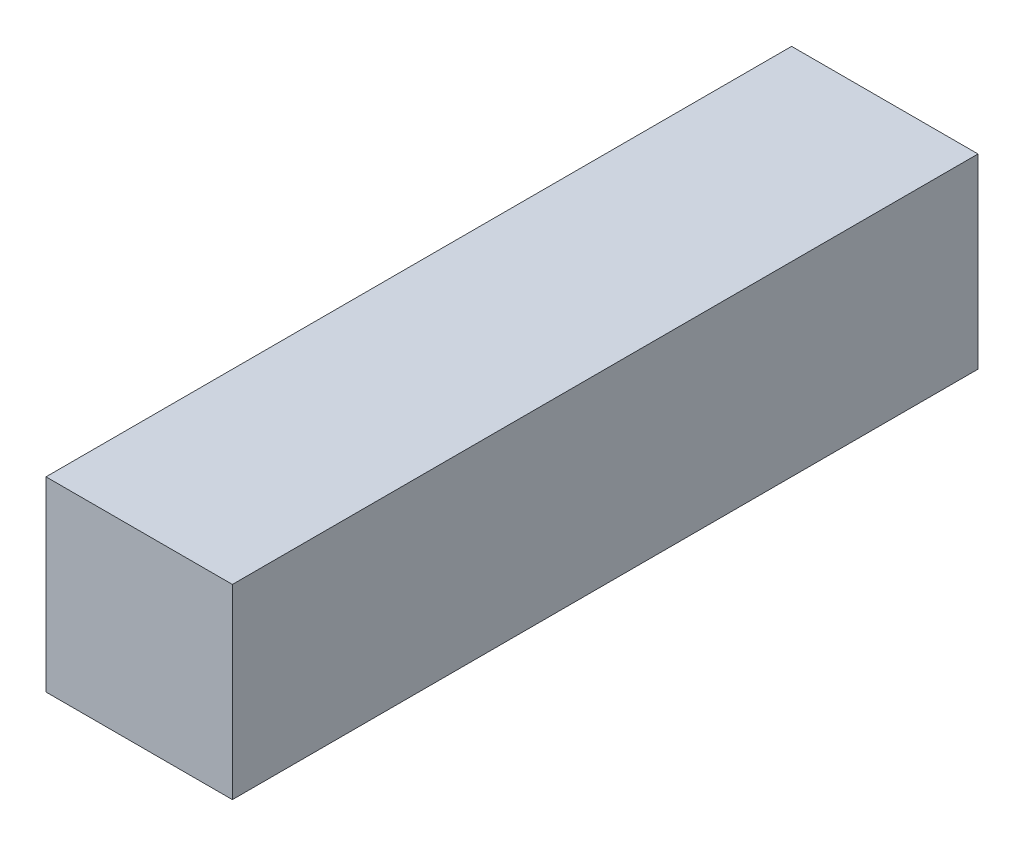
from build123d import *

# Parameters (mm, degrees)
SKETCH1_W           = 609.6
SKETCH1_H           = 152.4
BOSS_EXTRUDE1_DEPTH = 152.4


with BuildPart() as part:
    # Sketch1 → Boss-Extrude1 (new body)
    with BuildSketch(Plane(origin=(0, 0, 0), x_dir=(0, 0, -1), z_dir=(1, 0, 0))):
        with Locations((304.8, 76.2)):
            Rectangle(SKETCH1_W, SKETCH1_H)
    extrude(amount=BOSS_EXTRUDE1_DEPTH)


solid = part.part
